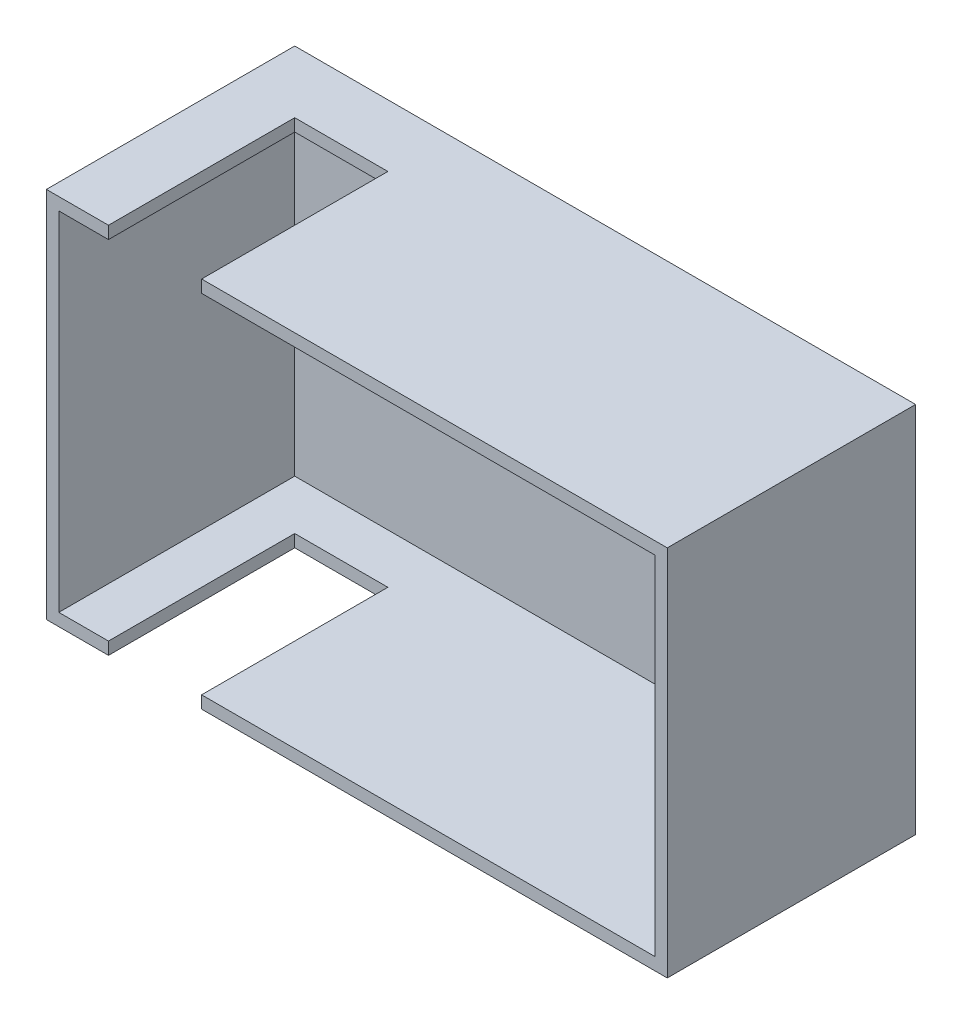
from build123d import *

# Parameters (mm, degrees)
SKETCH_1_W          = 100
SKETCH_1_H          = 60
EXTRUDE_1_DEPTH     = 40
SHELL_1_T           = -2
SKETCH_2_W          = 15
SKETCH_2_H          = 30
CUT_EXTRUDE_1_DEPTH = 60


with BuildPart() as part:
    # 草圖1 → 填料-伸長1 (new body)
    with BuildSketch(Plane.XY):
        Rectangle(SKETCH_1_W, SKETCH_1_H)
    extrude(amount=EXTRUDE_1_DEPTH)

    # 薄殼1
    shell_1_openings = [part.faces().sort_by_distance(p)[0] for p in [
        (0, 0, 40),
    ]]
    offset(amount=SHELL_1_T, openings=shell_1_openings, kind=Kind.INTERSECTION)

    # 草圖2 → 除料-伸長1 (cut)
    with BuildSketch(Plane.XZ.offset(30)):
        with Locations((-32.5, 25)):
            Rectangle(SKETCH_2_W, SKETCH_2_H)
    extrude(amount=-CUT_EXTRUDE_1_DEPTH, mode=Mode.SUBTRACT)


solid = part.part
